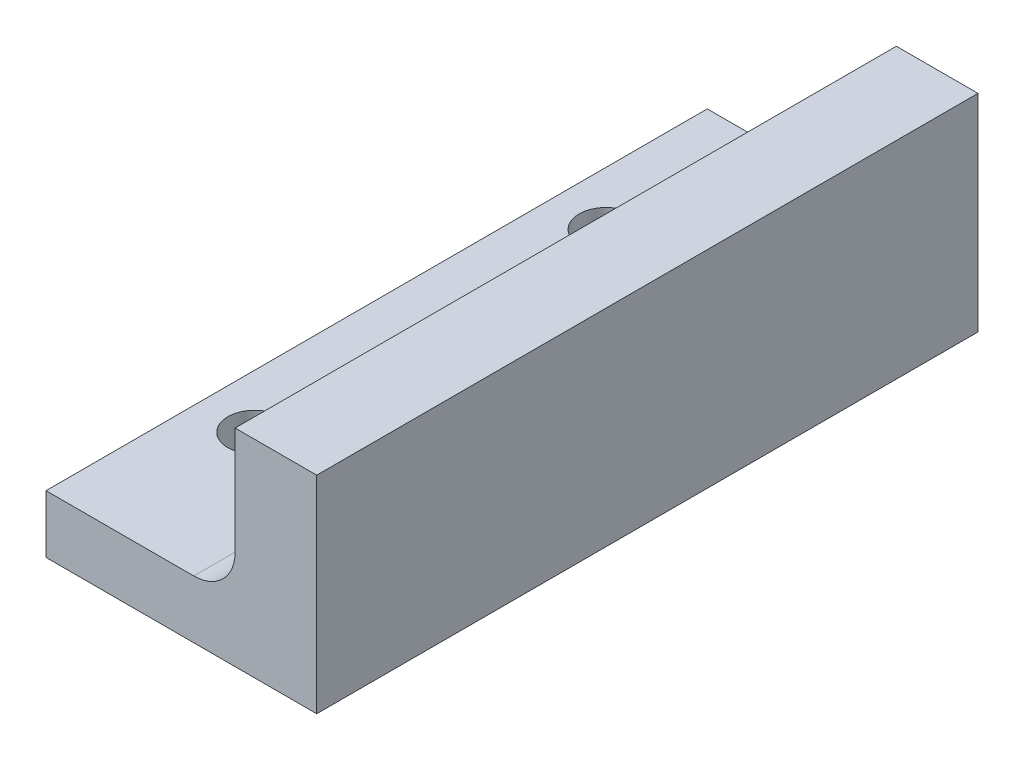
from build123d import *

# Parameters (mm, degrees)
SKETCH1_W           = 5.2
SKETCH1_H           = 32
SKETCH1_R           = 1.3
BOSS_EXTRUDE1_DEPTH = 2.8
SKETCH2_W           = 32
SKETCH2_H           = 10
BOSS_EXTRUDE2_DEPTH = 7.9
SKETCH3_W           = 3.95
SKETCH3_H           = 32
CUT_EXTRUDE1_DEPTH  = 7.2
FILLET1_R           = 2


with BuildPart() as part:
    # Sketch1 → Boss-Extrude1 (new body)
    with BuildSketch(Plane(origin=(0, 0, 0), x_dir=(1, 0, 0), z_dir=(0, 1, 0))):
        Rectangle(SKETCH1_W, SKETCH1_H)
        with Locations((0, -8.5)):
            Circle(SKETCH1_R, mode=Mode.SUBTRACT)
        with Locations((0, 8.5)):
            Circle(SKETCH1_R, mode=Mode.SUBTRACT)
    extrude(amount=BOSS_EXTRUDE1_DEPTH)

    # Sketch2 → Boss-Extrude2 (add)
    with BuildSketch(Plane(origin=(2.6, 0, 0), x_dir=(0, 0, -1), z_dir=(1, 0, 0))):
        with Locations((0, 5)):
            Rectangle(SKETCH2_W, SKETCH2_H)
    extrude(amount=BOSS_EXTRUDE2_DEPTH)

    # Sketch3 → Cut-Extrude1 (cut)
    with BuildSketch(Plane(origin=(0, 10, 0), x_dir=(1, 0, 0), z_dir=(0, 1, 0))):
        with Locations((4.575, 0)):
            Rectangle(SKETCH3_W, SKETCH3_H)
    extrude(amount=-CUT_EXTRUDE1_DEPTH, mode=Mode.SUBTRACT)

    # Fillet1
    fillet1_edges = [part.edges().sort_by_distance(p)[0] for p in [
        (6.55, 2.8, 0),
    ]]
    fillet(fillet1_edges, radius=FILLET1_R)


solid = part.part
